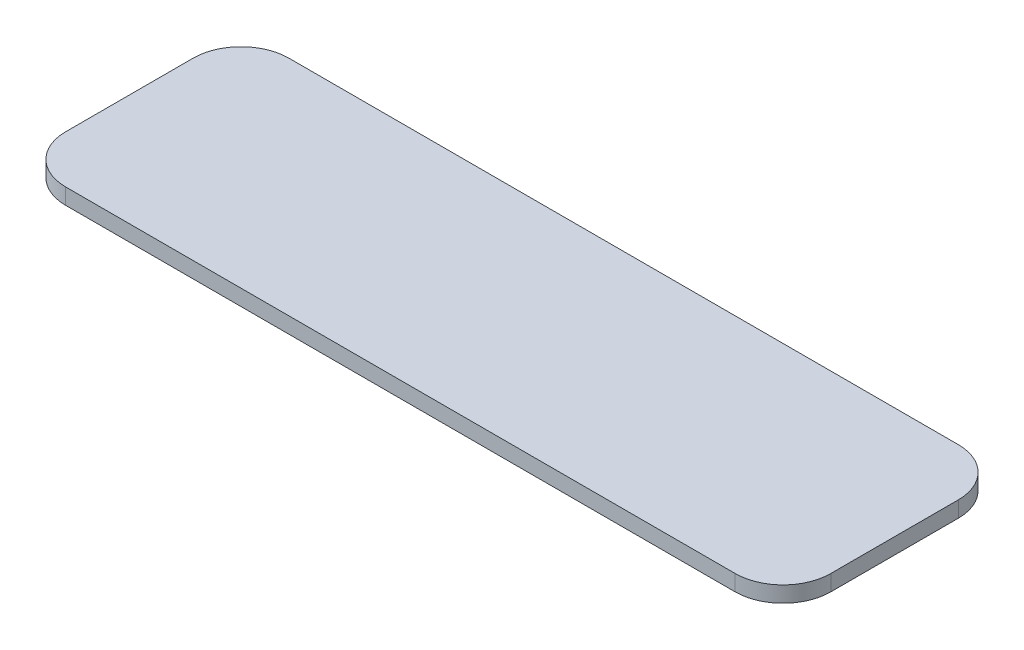
from build123d import *

# Parameters (mm, degrees)
EXTRUDE_1_DEPTH = 1.5


with BuildPart() as part:
    # 草图1 → 凸台-拉伸1 (new body)
    with BuildSketch(Plane(origin=(0, 0, 0), x_dir=(1, 0, 0), z_dir=(0, 1, 0))):
        with BuildLine():
            Line((-31.5, 10.5), (31.5, 10.5))
            ThreePointArc((31.5, 10.5), (34.681980515, 9.181980515), (36, 6))
            Line((36, 6), (36, -6))
            ThreePointArc((36, -6), (34.681980515, -9.181980515), (31.5, -10.5))
            Line((31.5, -10.5), (-31.5, -10.5))
            ThreePointArc((-31.5, -10.5), (-34.681980515, -9.181980515), (-36, -6))
            Line((-36, -6), (-36, 6))
            ThreePointArc((-36, 6), (-34.681980515, 9.181980515), (-31.5, 10.5))
        make_face()
    extrude(amount=EXTRUDE_1_DEPTH)


solid = part.part
